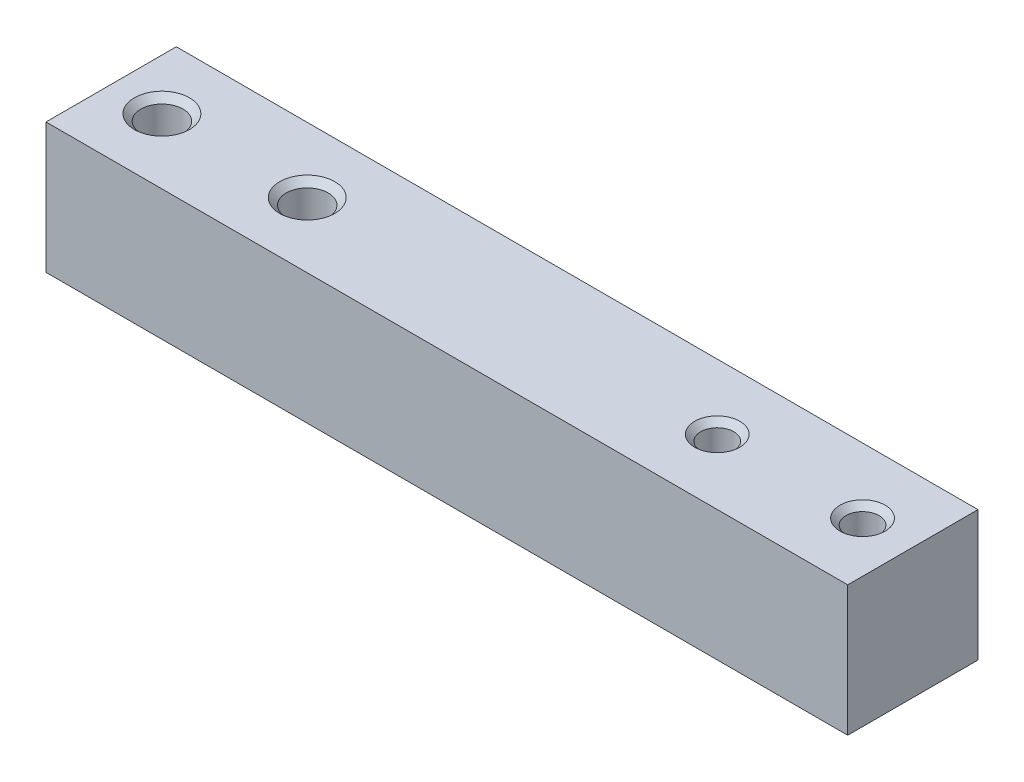
from build123d import *

# Parameters (mm, degrees)
SKETCH1_W                       = 80
SKETCH1_H                       = 13
BOSS_EXTRUDE1_DEPTH             = 13
M4X0_7_TAPPED_HOLE1_D           = 3.3
M4X0_7_TAPPED_HOLE1_CSINK_D     = 4.5
M4X0_7_TAPPED_HOLE1_CSINK_ANGLE = 90
M5X0_8_TAPPED_HOLE1_D           = 4.2
M5X0_8_TAPPED_HOLE1_CSINK_D     = 5.5
M5X0_8_TAPPED_HOLE1_CSINK_ANGLE = 90


with BuildPart() as part:
    # Sketch1 → Boss-Extrude1 (new body)
    with BuildSketch(Plane(origin=(0, 0, 0), x_dir=(1, 0, 0), z_dir=(0, 1, 0))):
        with Locations((40, 6.5)):
            Rectangle(SKETCH1_W, SKETCH1_H)
    extrude(amount=BOSS_EXTRUDE1_DEPTH)

    # M4x0.7 Tapped Hole1 (through all)
    with Locations(Plane(origin=(74.979, 13, -6.5), x_dir=(0, 0, 1), z_dir=(0, 1, 0))):
        with Locations((0, 0), (0, -14.5)):
            CounterSinkHole(M4X0_7_TAPPED_HOLE1_D / 2, M4X0_7_TAPPED_HOLE1_CSINK_D / 2, counter_sink_angle=M4X0_7_TAPPED_HOLE1_CSINK_ANGLE)

    # M5x0.8 Tapped Hole1 (through all)
    with Locations(Plane(origin=(5.067, 13, -6.5), x_dir=(0, 0, 1), z_dir=(0, 1, 0))):
        with Locations((0, 0), (0, 14.5)):
            CounterSinkHole(M5X0_8_TAPPED_HOLE1_D / 2, M5X0_8_TAPPED_HOLE1_CSINK_D / 2, counter_sink_angle=M5X0_8_TAPPED_HOLE1_CSINK_ANGLE)


solid = part.part
